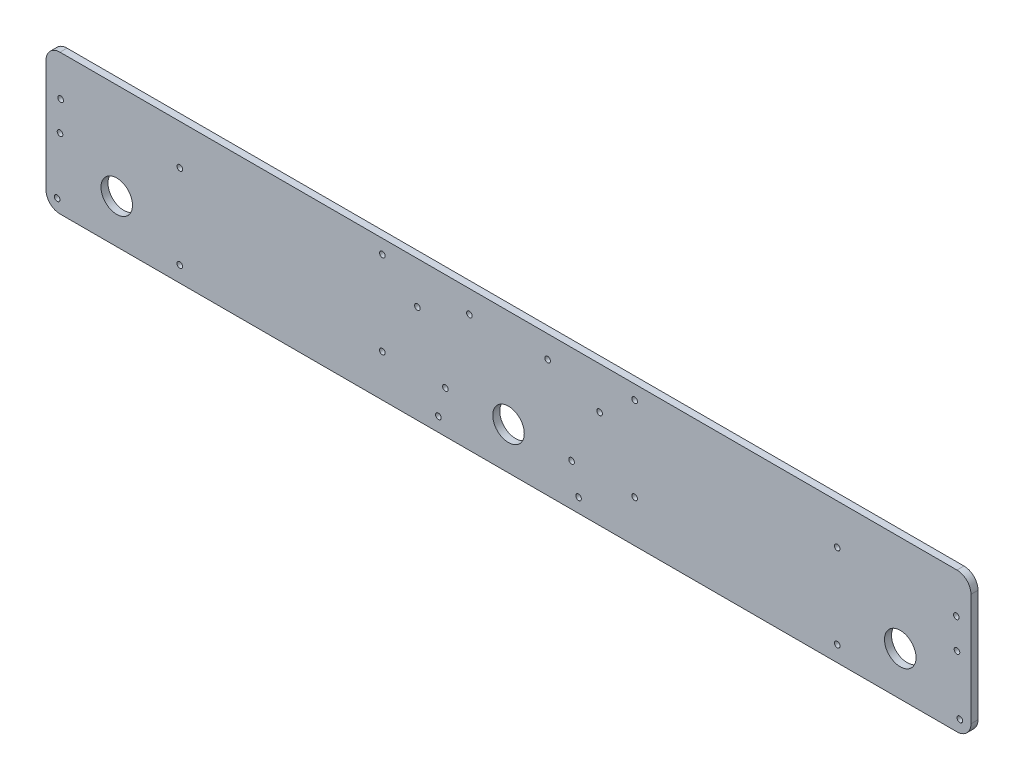
from build123d import *

# Parameters (mm, degrees)
SKETCH1_W           = 838.2
SKETCH1_H           = 127
BOSS_EXTRUDE1_DEPTH = 6.35
SKETCH2_R           = 14.2875
CUT_EXTRUDE1_DEPTH  = 6.35
SKETCH3_R           = 14.2875
CUT_EXTRUDE2_DEPTH  = 6.35
SKETCH4_R           = 2.5527
CUT_EXTRUDE3_DEPTH  = 6.35
SKETCH5_R           = 2.5527
CUT_EXTRUDE4_DEPTH  = 6.35
FILLET3_R           = 12.7
SKETCH6_R           = 2.5527
CUT_EXTRUDE5_DEPTH  = 6.35


with BuildPart() as part:
    # Sketch1 → Boss-Extrude1 (new body)
    with BuildSketch(Plane.XY):
        with Locations((0, 6.35)):
            Rectangle(SKETCH1_W, SKETCH1_H)
    extrude(amount=BOSS_EXTRUDE1_DEPTH)

    # Sketch2 → Cut-Extrude1 (cut)
    with BuildSketch(Plane.XY.offset(6.35)):
        with Locations((0, -19.05)):
            Circle(SKETCH2_R)
    extrude(amount=-CUT_EXTRUDE1_DEPTH, mode=Mode.SUBTRACT)

    # Sketch3 → Cut-Extrude2 (cut)
    with BuildSketch(Plane.XY.offset(6.35)):
        with Locations((-354.99802, -17.4625)):
            Circle(SKETCH3_R)
        with Locations((354.99802, -17.4625)):
            Circle(SKETCH3_R)
    extrude(amount=-CUT_EXTRUDE2_DEPTH, mode=Mode.SUBTRACT)

    # Sketch4 → Cut-Extrude3 (cut)
    with BuildSketch(Plane.XY.offset(6.35)):
        with Locations((-35.41268, 49.5808)):
            Circle(SKETCH4_R)
        with Locations((-57.15, -19.05)):
            Circle(SKETCH4_R)
        with Locations((57.15, -19.05)):
            Circle(SKETCH4_R)
        with Locations((35.41268, 49.5808)):
            Circle(SKETCH4_R)
    extrude(amount=-CUT_EXTRUDE3_DEPTH, mode=Mode.SUBTRACT)

    # Sketch5 → Cut-Extrude4 (cut)
    with BuildSketch(Plane.XY.offset(6.35)):
        with Locations((-405.79802, 33.3375)):
            Circle(SKETCH5_R)
        with Locations((408.97302, -46.0375)):
            Circle(SKETCH5_R)
        with Locations((405.79802, 33.3375)):
            Circle(SKETCH5_R)
        with Locations((63.5, -44.45)):
            Circle(SKETCH5_R)
        with Locations((-63.5, -44.45)):
            Circle(SKETCH5_R)
        with Locations((-297.84802, -42.8625)):
            Circle(SKETCH5_R)
        with Locations((297.84802, -42.8625)):
            Circle(SKETCH5_R)
        with Locations((-408.97302, -46.0375)):
            Circle(SKETCH5_R)
        with Locations((-297.84802, 33.3375)):
            Circle(SKETCH5_R)
        with Locations((297.84802, 33.3375)):
            Circle(SKETCH5_R)
        with Locations((82.55, 31.75)):
            Circle(SKETCH5_R)
        with Locations((-82.55, 31.75)):
            Circle(SKETCH5_R)
    extrude(amount=-CUT_EXTRUDE4_DEPTH, mode=Mode.SUBTRACT)

    # Fillet3
    fillet3_edges = [part.edges().sort_by_distance(p)[0] for p in [
        (-419.1, 69.85, 3.175),
        (419.1, 69.85, 3.175),
        (419.1, -57.15, 3.175),
        (-419.1, -57.15, 3.175),
    ]]
    fillet(fillet3_edges, radius=FILLET3_R)

    # Sketch6 → Cut-Extrude5 (cut)
    with BuildSketch(Plane.XY.offset(6.35)):
        with Locations((-406.4, 6.35)):
            Circle(SKETCH6_R)
        with Locations((406.4, 6.35)):
            Circle(SKETCH6_R)
        with Locations((-114.3, 57.15)):
            Circle(SKETCH6_R)
        with Locations((-114.3, -19.05)):
            Circle(SKETCH6_R)
        with Locations((114.3, 57.15)):
            Circle(SKETCH6_R)
        with Locations((114.3, -19.05)):
            Circle(SKETCH6_R)
    extrude(amount=-CUT_EXTRUDE5_DEPTH, mode=Mode.SUBTRACT)


solid = part.part
